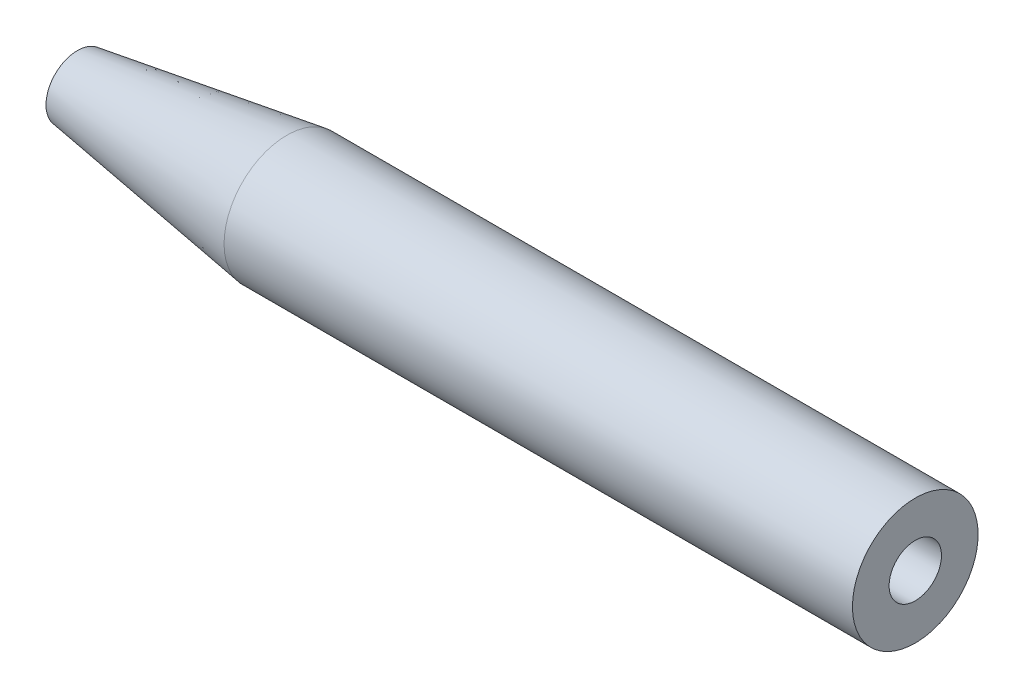
from build123d import *

# Parameters (mm, degrees)
M3X0_5_TAPPED_HOLE1_D     = 2.5
M3X0_5_TAPPED_HOLE1_DEPTH = 8.748924226
M3X0_5_TAPPED_HOLE1_TIP   = 0.751075774


with BuildPart() as part:
    # Sketch1 → Revolve1 (revolve)
    with BuildSketch(Plane(origin=(0, 0, 0), x_dir=(1, 0, 0), z_dir=(0, 1, 0))):
        Polygon((0, 0), (0, 3), (-30, 3), (-40, 1.5), (-40, 0), align=None)
    revolve(axis=Axis((0, 0, 0), (1, 0, 0)))

    # M3x0.5 Tapped Hole1
    with Locations(Plane(origin=(0, 0, 0), x_dir=(0, 0, -1), z_dir=(1, 0, 0))):
        with Locations((0, 0)):
            Hole(M3X0_5_TAPPED_HOLE1_D / 2, depth=M3X0_5_TAPPED_HOLE1_DEPTH)
            with Locations((0, 0, -(M3X0_5_TAPPED_HOLE1_DEPTH + M3X0_5_TAPPED_HOLE1_TIP / 2))):  # 118° drill point
                Cone(0, M3X0_5_TAPPED_HOLE1_D / 2, M3X0_5_TAPPED_HOLE1_TIP, mode=Mode.SUBTRACT)


solid = part.part
